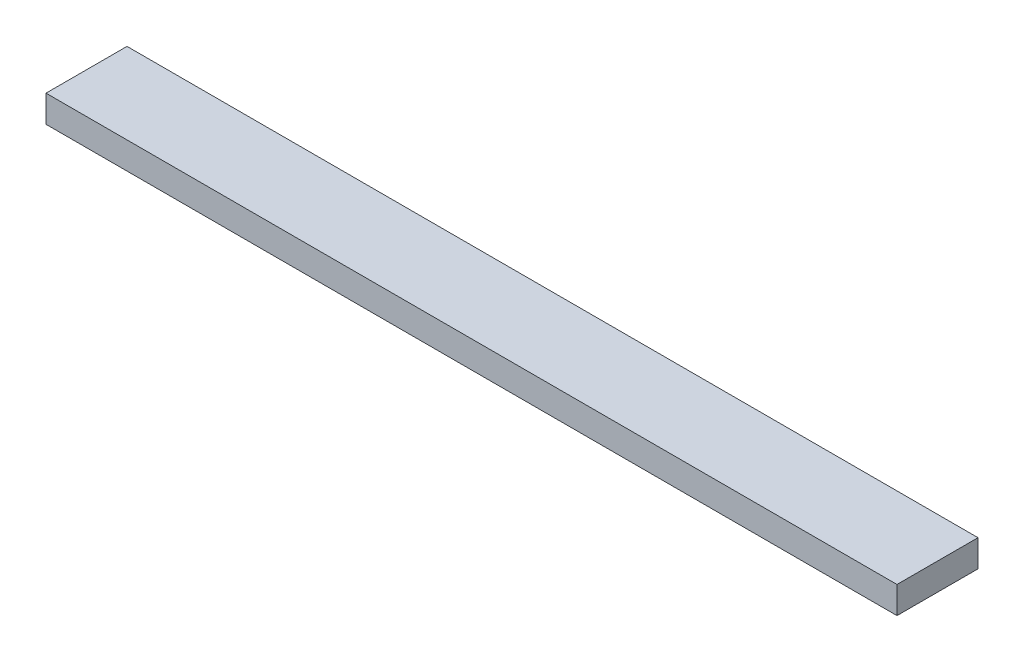
from build123d import *

# Parameters (mm, degrees)
SKETCH1_W           = 38.1
SKETCH1_H           = 12.7
BOSS_EXTRUDE1_DEPTH = 400.2


with BuildPart() as part:
    # Sketch1 → Boss-Extrude1 (new body)
    with BuildSketch(Plane(origin=(0, 0, 0), x_dir=(0, 0, -1), z_dir=(1, 0, 0))):
        with Locations((19.05, 6.35)):
            Rectangle(SKETCH1_W, SKETCH1_H)
    extrude(amount=BOSS_EXTRUDE1_DEPTH)


solid = part.part
